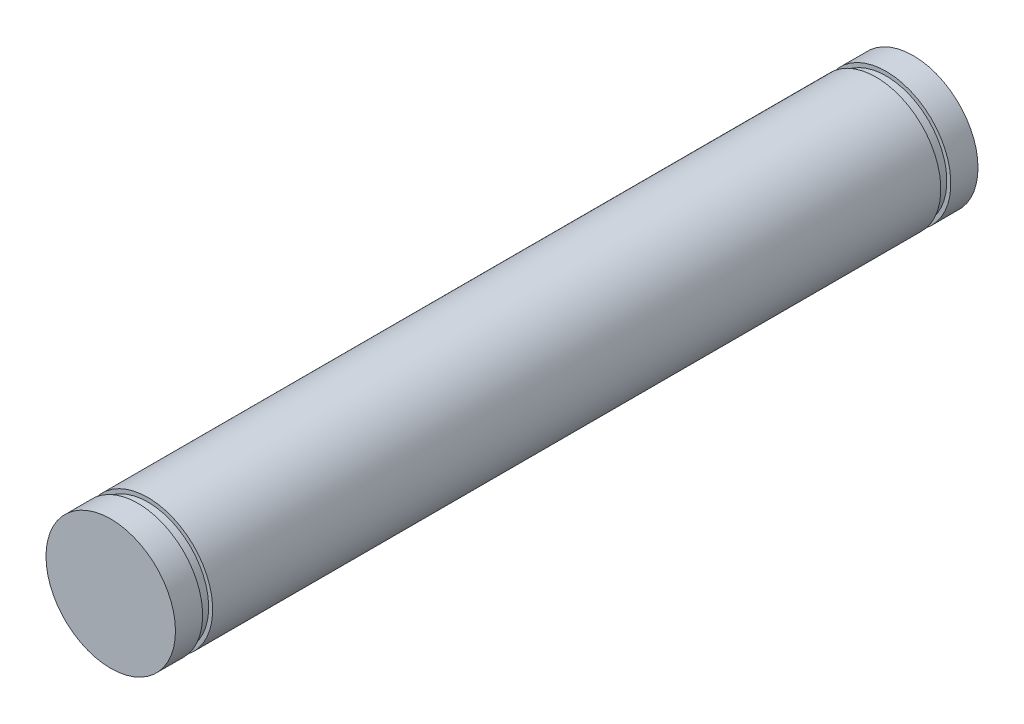
from build123d import *

# Parameters (mm, degrees)
SKETCH1_R           = 4.7625
BOSS_EXTRUDE1_DEPTH = 59.05
SKETCH2_W           = 0.2921
SKETCH2_H           = 0.7366


with BuildPart() as part:
    # Sketch1 → Boss-Extrude1 (new body)
    with BuildSketch(Plane.XY):
        Circle(SKETCH1_R)
    extrude(amount=BOSS_EXTRUDE1_DEPTH)

    # Sketch2 → Cut-Revolve1 (revolve, cut)
    with BuildSketch(Plane(origin=(0, 0, 0), x_dir=(1, 0, 0), z_dir=(0, 1, 0))):
        with Locations((-4.61645, -2.3683)):
            Rectangle(SKETCH2_W, SKETCH2_H)
        with Locations((-4.61645, -56.6817)):
            Rectangle(SKETCH2_W, SKETCH2_H)
    revolve(axis=Axis((0, 0, 0), (0, 0, 1)), mode=Mode.SUBTRACT)


solid = part.part
